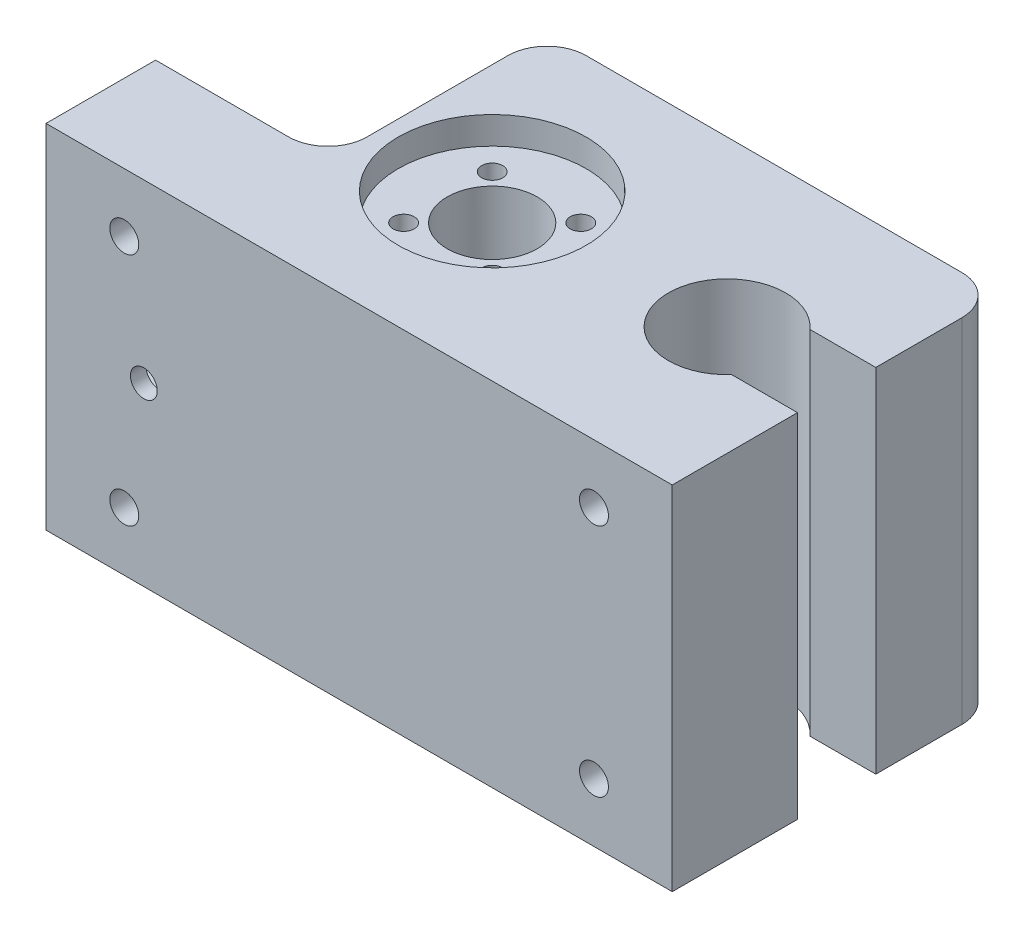
from build123d import *

# Parameters (mm, degrees)
SKETCH1_W           = 80
SKETCH1_H           = 45
BOSS_EXTRUDE1_DEPTH = 42
SKETCH3_W           = 22
SKETCH3_H           = 28
CUT_EXTRUDE2_DEPTH  = 46
SKETCH4_W           = 10
SKETCH4_H           = 17
CUT_EXTRUDE3_DEPTH  = 28
SKETCH7_R           = 12
CUT_EXTRUDE5_DEPTH  = 3.5
SKETCH11_R          = 1.35
CUT_EXTRUDE6_DEPTH  = 15
SKETCH12_R          = 5.75
CUT_EXTRUDE7_DEPTH  = 42.5
SKETCH13_R          = 7.5
CUT_EXTRUDE8_DEPTH  = 46
SKETCH14_W          = 12.099538741
SKETCH14_H          = 10
CUT_EXTRUDE9_DEPTH  = 46
SKETCH15_R          = 1.712332532
CUT_EXTRUDE10_DEPTH = 43
SKETCH16_R          = 1.85
CUT_EXTRUDE11_DEPTH = 8
FILLET2_R           = 5
SKETCH17_R          = 12.5
CUT_EXTRUDE12_DEPTH = 31


with BuildPart() as part:
    # Sketch1 → Boss-Extrude1 (new body)
    with BuildSketch(Plane.XY):
        with Locations((40, 22.5)):
            Rectangle(SKETCH1_W, SKETCH1_H)
    extrude(amount=BOSS_EXTRUDE1_DEPTH)

    # Sketch3 → Cut-Extrude2 (cut, through all)
    with BuildSketch(Plane(origin=(0, 45, 0), x_dir=(1, 0, 0), z_dir=(0, 1, 0))):
        with Locations((11, -14)):
            Rectangle(SKETCH3_W, SKETCH3_H)
    extrude(amount=-CUT_EXTRUDE2_DEPTH, mode=Mode.SUBTRACT)

    # Sketch4 → Cut-Extrude3 (cut)
    with BuildSketch(Plane.ZY):
        with Locations((35, 22.5)):
            Rectangle(SKETCH4_W, SKETCH4_H)
    extrude(amount=-CUT_EXTRUDE3_DEPTH, mode=Mode.SUBTRACT)

    # Sketch7 → Cut-Extrude5 (cut)
    with BuildSketch(Plane(origin=(0, 45, 0), x_dir=(1, 0, 0), z_dir=(0, 1, 0))):
        with Locations((36, -21)):
            Circle(SKETCH7_R)
    extrude(amount=-CUT_EXTRUDE5_DEPTH, mode=Mode.SUBTRACT)

    # Sketch11 → Cut-Extrude6 (cut)
    with BuildSketch(Plane(origin=(0, 41.5, 0), x_dir=(1, 0, 0), z_dir=(0, 1, 0))):
        with Locations((41.656854249, -15.343145751)):
            Circle(SKETCH11_R)
        with Locations((41.656854249, -26.656854249)):
            Circle(SKETCH11_R)
        with Locations((30.343145751, -26.656854249)):
            Circle(SKETCH11_R)
        with Locations((30.343145751, -15.343145751)):
            Circle(SKETCH11_R)
    extrude(amount=-CUT_EXTRUDE6_DEPTH, mode=Mode.SUBTRACT)

    # Sketch12 → Cut-Extrude7 (cut, through all)
    with BuildSketch(Plane(origin=(0, 41.5, 0), x_dir=(1, 0, 0), z_dir=(0, 1, 0))):
        with Locations((36, -21)):
            Circle(SKETCH12_R)
    extrude(amount=-CUT_EXTRUDE7_DEPTH, mode=Mode.SUBTRACT)

    # Sketch13 → Cut-Extrude8 (cut, through all)
    with BuildSketch(Plane(origin=(0, 45, 0), x_dir=(1, 0, 0), z_dir=(0, 1, 0))):
        with Locations((66, -21)):
            Circle(SKETCH13_R)
    extrude(amount=-CUT_EXTRUDE8_DEPTH, mode=Mode.SUBTRACT)

    # Sketch14 → Cut-Extrude9 (cut, through all)
    with BuildSketch(Plane(origin=(0, 45, 0), x_dir=(1, 0, 0), z_dir=(0, 1, 0))):
        with Locations((73.950230629, -21)):
            Rectangle(SKETCH14_W, SKETCH14_H)
    extrude(amount=-CUT_EXTRUDE9_DEPTH, mode=Mode.SUBTRACT)

    # Sketch15 → Cut-Extrude10 (cut, through all)
    with BuildSketch(Plane.XY.offset(42)):
        with Locations((12.5, 22.500000001)):
            Circle(SKETCH15_R)
    extrude(amount=-CUT_EXTRUDE10_DEPTH, mode=Mode.SUBTRACT)

    # Sketch16 → Cut-Extrude11 (cut)
    with BuildSketch(Plane.XY.offset(42)):
        with Locations((10, 37.5)):
            Circle(SKETCH16_R)
        with Locations((70, 37.5)):
            Circle(SKETCH16_R)
        with Locations((70, 7.5)):
            Circle(SKETCH16_R)
        with Locations((10, 7.5)):
            Circle(SKETCH16_R)
    extrude(amount=-CUT_EXTRUDE11_DEPTH, mode=Mode.SUBTRACT)

    # Fillet2
    fillet2_edges = [part.edges().sort_by_distance(p)[0] for p in [
        (22, 22.5, 0),
        (22, 22.5, 28),
        (80, 22.5, 0),
    ]]
    fillet(fillet2_edges, radius=FILLET2_R)

    # Sketch17 → Cut-Extrude12 (cut)
    with BuildSketch(Plane.XZ):
        with Locations((36, 21)):
            Circle(SKETCH17_R)
    extrude(amount=-CUT_EXTRUDE12_DEPTH, mode=Mode.SUBTRACT)


solid = part.part
